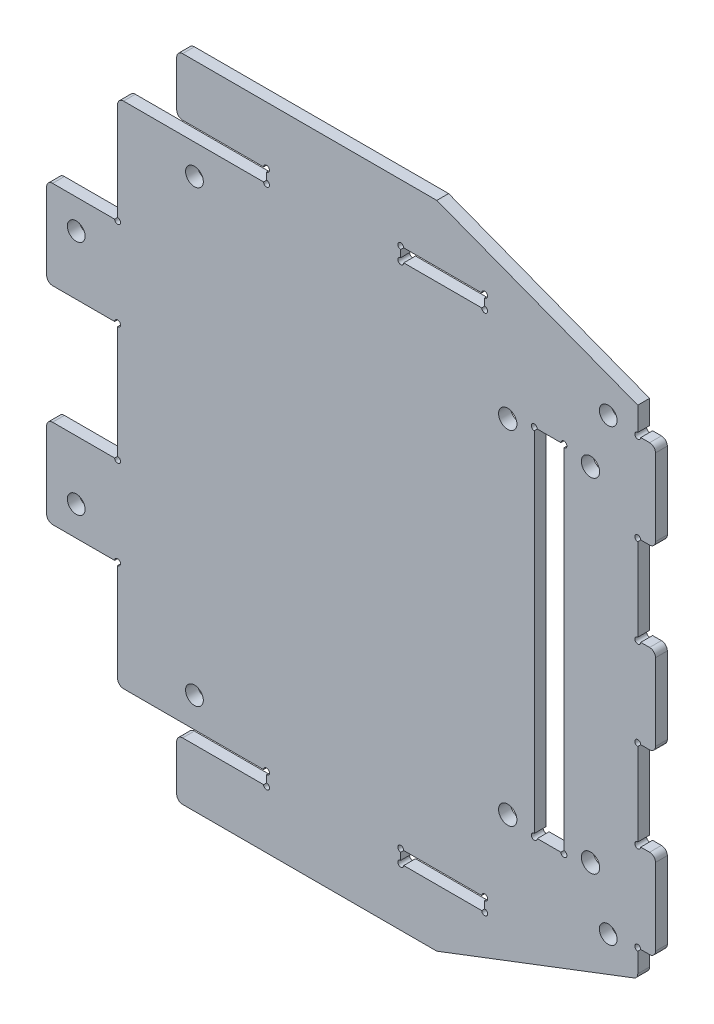
from build123d import *

# Parameters (mm, degrees)
SKETCH_1_R          = 1.5
SKETCH_1_W          = 14.2
SKETCH_1_H          = 2.2
EXTRUDE_1_DEPTH     = 2
SKETCH_2_R          = 0.5
CUT_EXTRUDE_1_DEPTH = 3
FILLET_1_R          = 1
SKETCH_3_R          = 1.55
SKETCH_3_W          = 5
SKETCH_3_H          = 60
CUT_EXTRUDE_2_DEPTH = 3
SKETCH_4_R          = 0.5
CUT_EXTRUDE_3_DEPTH = 3
SKETCH_5_W          = 10
SKETCH_5_H          = 9.75
CUT_EXTRUDE_4_DEPTH = 10
FILLET_2_R          = 1


with BuildPart() as part:
    # 草图1 → 凸台-拉伸1 (new body)
    with BuildSketch(Plane.XY):
        Polygon((44, 42), (10, 55), (-44, 55), (-44, 45.25), (-18.8, 45.25), (-18.8, 43.05), (-44, 43.05), (-44, 25), (-56, 25), (-56, 10), (-44, 10), (-44, -10), (-56, -10), (-56, -25), (-44, -25), (-44, -43.05), (-18.8, -43.05), (-18.8, -45.25), (-44, -45.25), (-44, -55), (10, -55), (44, -42), (44, -37.5), (47, -37.5), (47, -22.5), (44, -22.5), (44, -7.5), (47, -7.5), (47, 7.5), (44, 7.5), (44, 22.5), (47, 22.5), (47, 37.5), (44, 37.5), align=None)
        with Locations((-39, -50)):
            Circle(SKETCH_1_R, mode=Mode.SUBTRACT)
        with Locations((-31, -38)):
            Circle(SKETCH_1_R, mode=Mode.SUBTRACT)
        with Locations((11, -44.15)):
            Rectangle(SKETCH_1_W, SKETCH_1_H, mode=Mode.SUBTRACT)
        with Locations((39, -38)):
            Circle(SKETCH_1_R, mode=Mode.SUBTRACT)
        with Locations((-31, 38)):
            Circle(SKETCH_1_R, mode=Mode.SUBTRACT)
        with Locations((-39, 50)):
            Circle(SKETCH_1_R, mode=Mode.SUBTRACT)
        with Locations((11, 44.15)):
            Rectangle(SKETCH_1_W, SKETCH_1_H, mode=Mode.SUBTRACT)
        with Locations((39, 38)):
            Circle(SKETCH_1_R, mode=Mode.SUBTRACT)
        with Locations((-51, 20)):
            Circle(SKETCH_1_R, mode=Mode.SUBTRACT)
        with Locations((-51, -20)):
            Circle(SKETCH_1_R, mode=Mode.SUBTRACT)
    extrude(amount=EXTRUDE_1_DEPTH)

    # 草图2 → 切除-拉伸1 (cut, through all)
    with BuildSketch(Plane.XY.offset(2)):
        with Locations((-18.8, -45.25)):
            Circle(SKETCH_2_R)
        with Locations((-18.8, -43.05)):
            Circle(SKETCH_2_R)
        with Locations((3.9, -45.25)):
            Circle(SKETCH_2_R)
        with Locations((3.9, -43.05)):
            Circle(SKETCH_2_R)
        with Locations((18.1, -43.05)):
            Circle(SKETCH_2_R)
        with Locations((18.1, -45.25)):
            Circle(SKETCH_2_R)
        with Locations((18.1, 45.25)):
            Circle(SKETCH_2_R)
        with Locations((18.1, 43.05)):
            Circle(SKETCH_2_R)
        with Locations((3.9, 43.05)):
            Circle(SKETCH_2_R)
        with Locations((3.9, 45.25)):
            Circle(SKETCH_2_R)
        with Locations((-18.8, 43.05)):
            Circle(SKETCH_2_R)
        with Locations((-18.8, 45.25)):
            Circle(SKETCH_2_R)
        with Locations((-44, -25)):
            Circle(SKETCH_2_R)
        with Locations((-44, -10)):
            Circle(SKETCH_2_R)
        with Locations((-44, 10)):
            Circle(SKETCH_2_R)
        with Locations((-44, 25)):
            Circle(SKETCH_2_R)
        with Locations((44, -37.5)):
            Circle(SKETCH_2_R)
        with Locations((44, -22.5)):
            Circle(SKETCH_2_R)
        with Locations((44, -7.5)):
            Circle(SKETCH_2_R)
        with Locations((44, 22.5)):
            Circle(SKETCH_2_R)
        with Locations((44, 37.5)):
            Circle(SKETCH_2_R)
        with Locations((44, 7.5)):
            Circle(SKETCH_2_R)
    extrude(amount=-CUT_EXTRUDE_1_DEPTH, mode=Mode.SUBTRACT)

    # 圆角1
    fillet_1_edges = [part.edges().sort_by_distance(p)[0] for p in [
        (-44, -55, 1),
        (-44, -45.25, 1),
        (-44, -43.05, 1),
        (-56, -25, 1),
        (-56, -10, 1),
        (-56, 10, 1),
        (-56, 25, 1),
        (-44, 43.05, 1),
        (-44, 45.25, 1),
        (-44, 55, 1),
        (47, 37.5, 1),
        (47, 22.5, 1),
        (47, 7.5, 1),
        (47, -7.5, 1),
        (47, -22.5, 1),
        (47, -37.5, 1),
        (44, -42, 1),
    ]]
    fillet(fillet_1_edges, radius=FILLET_1_R)

    # 草图3 → 切除-拉伸2 (cut, through all)
    with BuildSketch(Plane(origin=(0, 0, 0), x_dir=(-1, 0, 0), z_dir=(0, 0, -1))):
        with Locations((-36, 29)):
            Circle(SKETCH_3_R)
        with Locations((-36, -29)):
            Circle(SKETCH_3_R)
        with Locations((-22, 29)):
            Circle(SKETCH_3_R)
        with Locations((-22, -29)):
            Circle(SKETCH_3_R)
        with Locations((-29, 0)):
            Rectangle(SKETCH_3_W, SKETCH_3_H)
    extrude(amount=-CUT_EXTRUDE_2_DEPTH, mode=Mode.SUBTRACT)

    # 草图4 → 切除-拉伸3 (cut, through all)
    with BuildSketch(Plane(origin=(0, 0, 0), x_dir=(-1, 0, 0), z_dir=(0, 0, -1))):
        with Locations((-31.5, 30)):
            Circle(SKETCH_4_R)
        with Locations((-26.5, 30)):
            Circle(SKETCH_4_R)
        with Locations((-31.5, -30)):
            Circle(SKETCH_4_R)
        with Locations((-26.5, -30)):
            Circle(SKETCH_4_R)
    extrude(amount=-CUT_EXTRUDE_3_DEPTH, mode=Mode.SUBTRACT)

    # 草图5 → 切除-拉伸4 (cut)
    with BuildSketch(Plane.XY.offset(2)):
        with Locations((-39, 50.125)):
            Rectangle(SKETCH_5_W, SKETCH_5_H)
        with Locations((-39, -50.125)):
            Rectangle(SKETCH_5_W, SKETCH_5_H)
    extrude(amount=-CUT_EXTRUDE_4_DEPTH, mode=Mode.SUBTRACT)

    # 圆角2
    fillet_2_edges = [part.edges().sort_by_distance(p)[0] for p in [
        (-34, 55, 1),
        (-34, 45.25, 1),
        (-34, -45.25, 1),
        (-34, -55, 1),
    ]]
    fillet(fillet_2_edges, radius=FILLET_2_R)


solid = part.part
